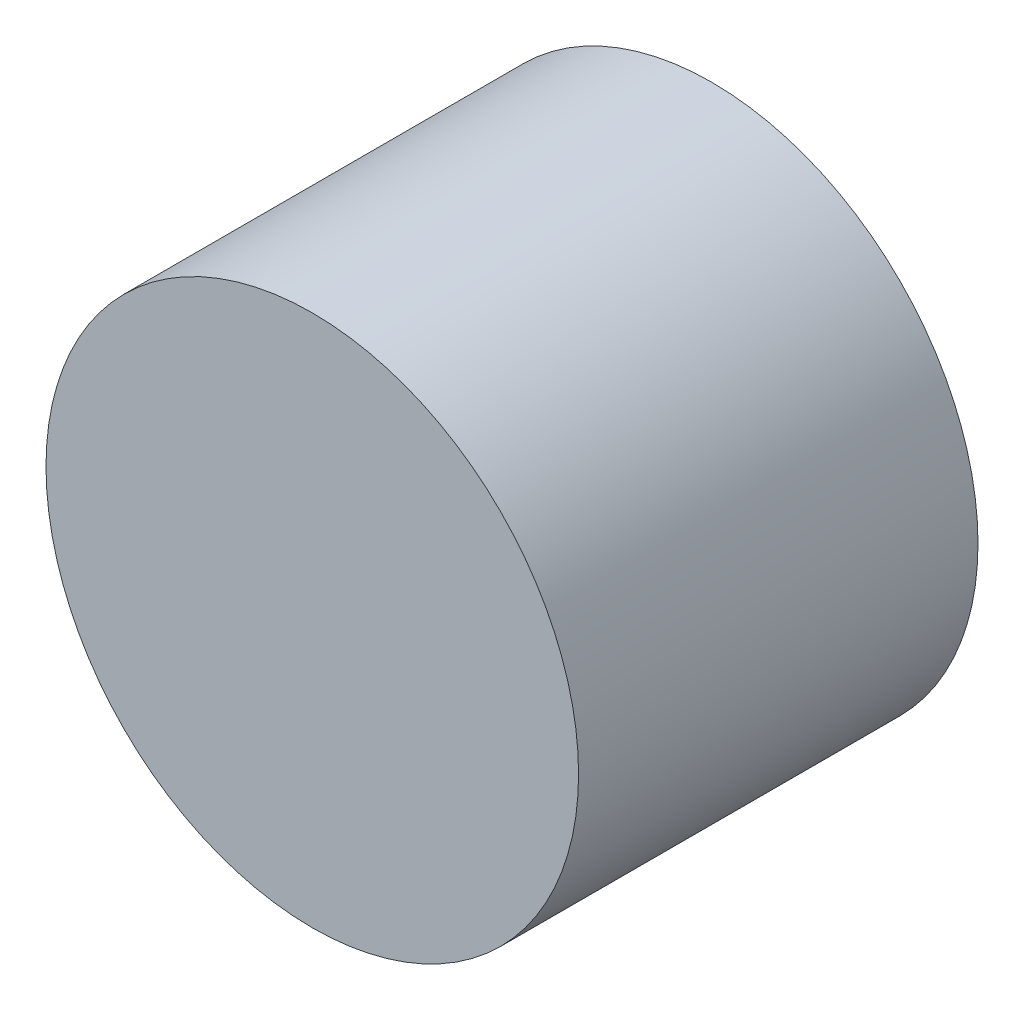
from build123d import *

# Parameters (mm, degrees)
SKETCH_1_R      = 10
EXTRUDE_1_DEPTH = 15


with BuildPart() as part:
    # ｽｹｯﾁ1 → ﾎﾞｽ - 押し出し1 (new body)
    with BuildSketch(Plane.XY):
        Circle(SKETCH_1_R)
    extrude(amount=EXTRUDE_1_DEPTH)


solid = part.part
